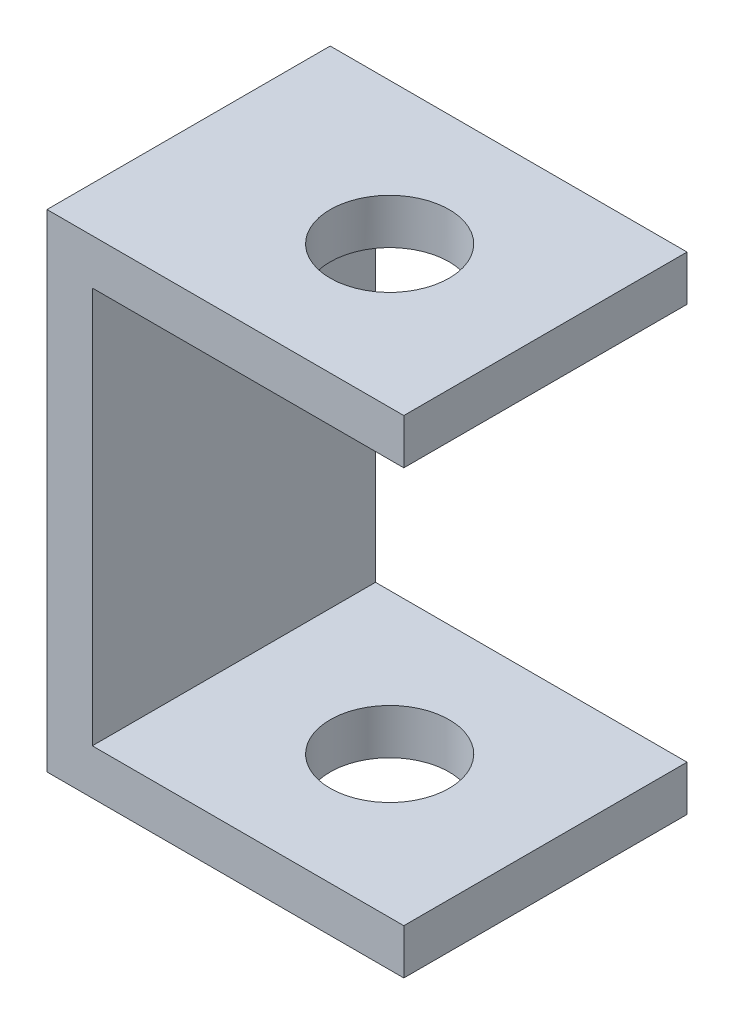
from build123d import *

# Parameters (mm, degrees)
DODANIE_WYCI_GNI_CIE1_DEPTH = 50
SZKIC2_R                    = 10.5
WYTNIJ_WYCI_GNI_CIE1_DEPTH  = 87


with BuildPart() as part:
    # Szkic1 → Dodanie-wyciągnięcie1 (new body)
    with BuildSketch(Plane.XY):
        Polygon((0, 0), (-63, 0), (-63, 86), (0, 86), (0, 78), (-55, 78), (-55, 8), (0, 8), align=None)
    extrude(amount=DODANIE_WYCI_GNI_CIE1_DEPTH)

    # Szkic2 → Wytnij-wyciągnięcie1 (cut, through all)
    with BuildSketch(Plane(origin=(0, 86, 0), x_dir=(1, 0, 0), z_dir=(0, 1, 0))):
        with Locations((-27.5, -25)):
            Circle(SZKIC2_R)
    extrude(amount=-WYTNIJ_WYCI_GNI_CIE1_DEPTH, mode=Mode.SUBTRACT)


solid = part.part
